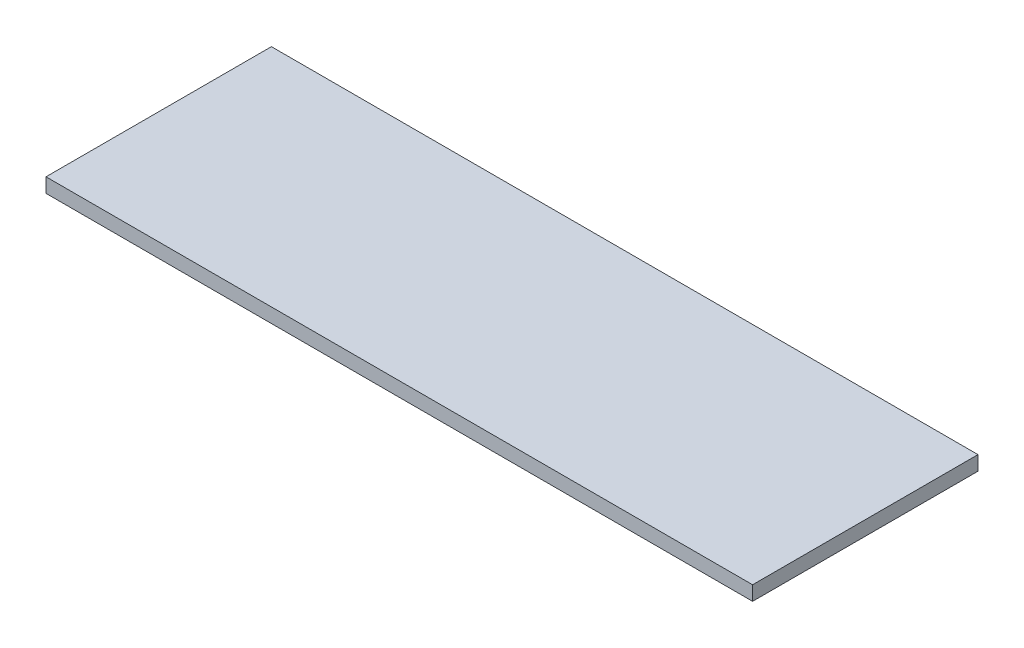
from build123d import *

# Parameters (mm, degrees)
SKETCH_1_W      = 884
SKETCH_1_H      = 282
EXTRUDE_1_DEPTH = 18


with BuildPart() as part:
    # Эскиз1 → Бобышка-Вытянуть1 (new body)
    with BuildSketch(Plane(origin=(0, 0, 0), x_dir=(1, 0, 0), z_dir=(0, 1, 0))):
        Rectangle(SKETCH_1_W, SKETCH_1_H)
    extrude(amount=EXTRUDE_1_DEPTH)


solid = part.part
